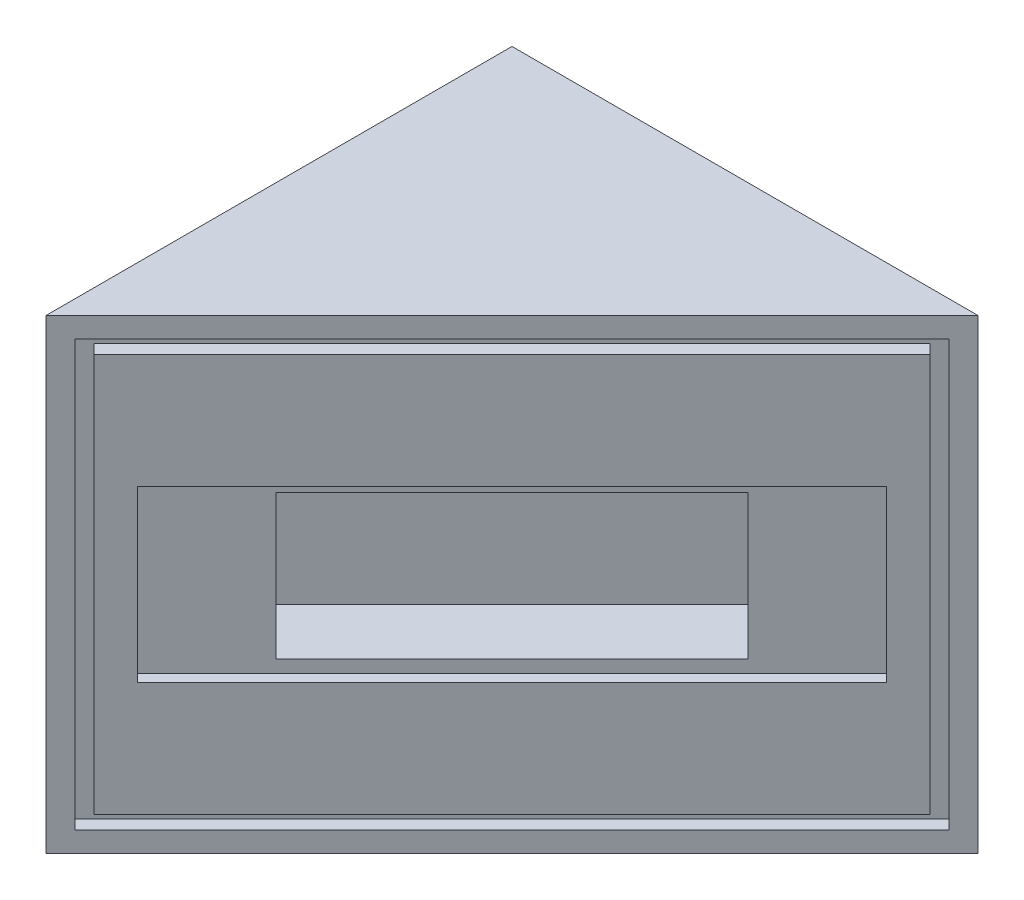
from build123d import *

# Parameters (mm, degrees)
SKETCH1_W           = 69.85
SKETCH1_H           = 69.85
BOSS_EXTRUDE1_DEPTH = 69.85
CUT_EXTRUDE2_DEPTH  = 100
SKETCH3_W           = 92.686817332
SKETCH3_H           = 63.754
SKETCH3_W_2         = 88.622817332
SKETCH3_H_2         = 59.69
CUT_EXTRUDE4_DEPTH  = 2.032
SKETCH4_W           = 79.375
SKETCH4_H           = 25.4
CUT_EXTRUDE5_DEPTH  = 1.6
SKETCH5_W           = 50
SKETCH5_H           = 21.59
CUT_EXTRUDE6_DEPTH  = 10


with BuildPart() as part:
    # Sketch1 → Boss-Extrude1 (new body)
    with BuildSketch(Plane(origin=(0, 0, 0), x_dir=(1, 0, 0), z_dir=(0, 1, 0))):
        with Locations((34.925, 34.925)):
            Rectangle(SKETCH1_W, SKETCH1_H)
    extrude(amount=BOSS_EXTRUDE1_DEPTH)

    # Sketch2 → Cut-Extrude2 (cut)
    with BuildSketch(Plane(origin=(0, 0, 0), x_dir=(0.707106781, 0, -0.707106781), z_dir=(0.707106781, 0, 0.707106781))):
        Polygon((98.782817332, 69.85), (98.782817332, 0), (49.391408666, 0), (0, 0), (0, 69.85), (49.391408666, 69.85), align=None)
    extrude(amount=CUT_EXTRUDE2_DEPTH, mode=Mode.SUBTRACT)

    # Sketch3 → Cut-Extrude4 (cut)
    with BuildSketch(Plane(origin=(0, 0, 0), x_dir=(0.707106781, 0, -0.707106781), z_dir=(0.707106781, 0, 0.707106781))):
        with Locations((49.391408666, 34.925)):
            Rectangle(SKETCH3_W, SKETCH3_H)
        with Locations((49.391408666, 34.925)):
            Rectangle(SKETCH3_W_2, SKETCH3_H_2, mode=Mode.SUBTRACT)
    extrude(amount=-CUT_EXTRUDE4_DEPTH, mode=Mode.SUBTRACT)

    # Sketch4 → Cut-Extrude5 (cut)
    with BuildSketch(Plane(origin=(0, 0, 0), x_dir=(0.707106781, 0, -0.707106781), z_dir=(0.707106781, 0, 0.707106781))):
        with Locations((49.391408666, 34.925)):
            Rectangle(SKETCH4_W, SKETCH4_H)
    extrude(amount=-CUT_EXTRUDE5_DEPTH, mode=Mode.SUBTRACT)

    # Sketch5 → Cut-Extrude6 (cut)
    with BuildSketch(Plane(origin=(-1.13137085, 0, -1.13137085), x_dir=(0.707106781, 0, -0.707106781), z_dir=(0.707106781, 0, 0.707106781))):
        with Locations((49.391408666, 34.925)):
            Rectangle(SKETCH5_W, SKETCH5_H)
    extrude(amount=-CUT_EXTRUDE6_DEPTH, mode=Mode.SUBTRACT)


solid = part.part
